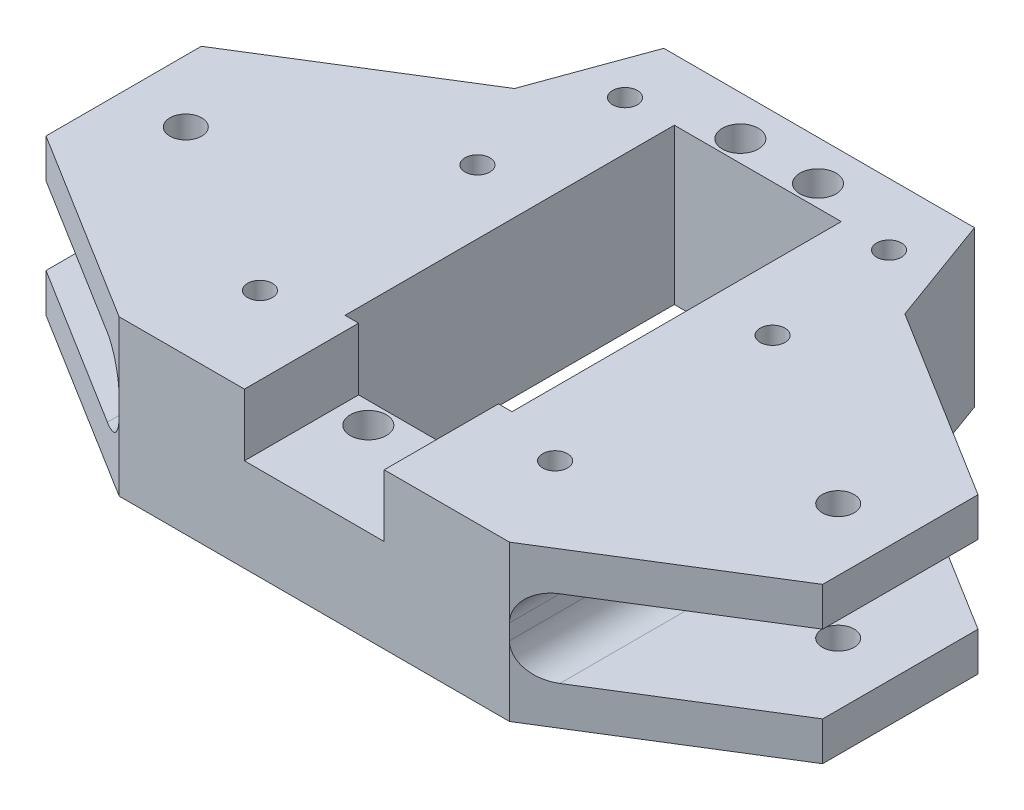
from build123d import *

# Parameters (mm, degrees)
MAIN_BODY_DEPTH           = 10
SKETCH2_R                 = 2.325
SKETCH2_R_2               = 2.05
SKETCH2_W                 = 21.5
SKETCH2_H                 = 42.4
SERVO_ROTROD_CUTOUT_DEPTH = 30
SKETCH3_W                 = 18
SKETCH3_H                 = 8
SERVO_CABLE_CUTOUT_DEPTH  = 57.102305
CONTROL_ARM_CUTOUT_START  = -66
SKETCH4_W                 = 24.86969785
SKETCH4_H                 = 10
CONTROL_ARM_CUTOUT_DEPTH  = 67
FILLET1_R                 = 4
SKETCH6_R                 = 1.6
MOUNT_HOLES_CHASSIS_DEPTH = 21
SKETCH7_R                 = 3.25
BOLT_HEAD_HOLES_DEPTH     = 4.5


with BuildPart() as part:
    # Sketch1 → Main-Body (new body, symmetric)
    with BuildSketch(Plane(origin=(0, 0, 0), x_dir=(1, 0, 0), z_dir=(0, 1, 0))):
        Polygon((20, 39.547694656), (-20, 39.547694656), (-25.13030215, 25.452305344), (-50, 10), (-50, -10), (-25.13030215, -25.452305344), (25.13030215, -25.452305344), (50, -10), (50, 10), (25.13030215, 25.452305344), align=None)
    extrude(amount=MAIN_BODY_DEPTH, both=True)

    # Sketch2 → Servo&RotRod-Cutout (cut)
    with BuildSketch(Plane(origin=(0, 10, 0), x_dir=(1, 0, 0), z_dir=(0, 1, 0))):
        with Locations((-5, -13.5)):
            Circle(SKETCH2_R)
        with Locations((5, -13.5)):
            Circle(SKETCH2_R)
        with Locations((-5, 34.4)):
            Circle(SKETCH2_R)
        with Locations((5, 34.4)):
            Circle(SKETCH2_R)
        with Locations((-42, 0)):
            Circle(SKETCH2_R_2)
        with Locations((42, 0)):
            Circle(SKETCH2_R_2)
        with Locations((0, 10.45)):
            Rectangle(SKETCH2_W, SKETCH2_H)
    extrude(amount=-SERVO_ROTROD_CUTOUT_DEPTH, mode=Mode.SUBTRACT)

    # Sketch3 → Servo-Cable-Cutout (cut)
    with BuildSketch(Plane.XY.offset(25.452305344)):
        with Locations((0, 6)):
            Rectangle(SKETCH3_W, SKETCH3_H)
    extrude(amount=-SERVO_CABLE_CUTOUT_DEPTH, mode=Mode.SUBTRACT)

    # Sketch4 → Control-Arm-Cutout (cut)
    with BuildSketch(Plane.XY.offset(25.452305344).offset(CONTROL_ARM_CUTOUT_START)):
        with Locations((-37.565151075, 0)):
            Rectangle(SKETCH4_W, SKETCH4_H)
    control_arm_cutout = extrude(amount=CONTROL_ARM_CUTOUT_DEPTH, mode=Mode.SUBTRACT)

    # Mirror1: Control-Arm-Cutout across plane
    add(control_arm_cutout.mirror(Plane(origin=(0, 0, 0), x_dir=(0, 0, 1), z_dir=(1, 0, 0))), mode=Mode.SUBTRACT)

    # Fillet1
    fillet1_edges = [part.edges().sort_by_distance(p)[0] for p in [
        (-25.13030215, 5, 0),
        (-25.13030215, -5, 0),
        (25.13030215, -5, 0),
        (25.13030215, 5, 0),
    ]]
    fillet(fillet1_edges, radius=FILLET1_R)

    # Sketch6 → Mount-Holes-Chassis (cut, through all)
    with BuildSketch(Plane.XZ.offset(10)):
        with Locations((19, -14.547694656)):
            Circle(SKETCH6_R)
        with Locations((19, 13.452305344)):
            Circle(SKETCH6_R)
        with Locations((17, -31.547694656)):
            Circle(SKETCH6_R)
        with Locations((-17, -31.547694656)):
            Circle(SKETCH6_R)
        with Locations((-19, 13.452305344)):
            Circle(SKETCH6_R)
        with Locations((-19, -14.547694656)):
            Circle(SKETCH6_R)
    extrude(amount=-MOUNT_HOLES_CHASSIS_DEPTH, mode=Mode.SUBTRACT)

    # Sketch7 → Bolt-Head-Holes (cut)
    with BuildSketch(Plane.XZ.offset(10)):
        with Locations((17, -31.547694656)):
            Circle(SKETCH7_R)
        with Locations((19, -14.547694656)):
            Circle(SKETCH7_R)
        with Locations((19, 13.452305344)):
            Circle(SKETCH7_R)
        with Locations((-19, 13.452305344)):
            Circle(SKETCH7_R)
        with Locations((-19, -14.547694656)):
            Circle(SKETCH7_R)
        with Locations((-17, -31.547694656)):
            Circle(SKETCH7_R)
    extrude(amount=-BOLT_HEAD_HOLES_DEPTH, mode=Mode.SUBTRACT)


solid = part.part
